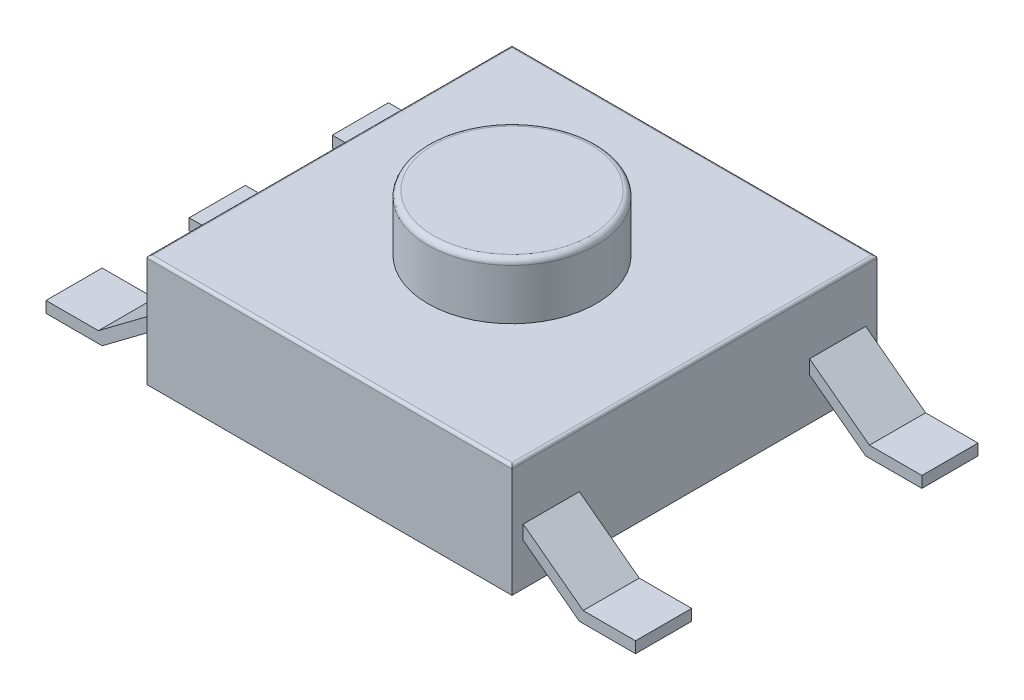
from build123d import *

# Parameters (mm, degrees)
SKETCH1_W           = 6.5
SKETCH1_H           = 6.5
BOSS_EXTRUDE1_DEPTH = 2
SKETCH2_R           = 1.5
BOSS_EXTRUDE2_DEPTH = 1
FILLET1_R           = 0.1
FILLET2_R           = 0.05
BOSS_EXTRUDE3_DEPTH = 6.5
SKETCH4_W           = 2
SKETCH4_H           = 1.55
SKETCH4_H_2         = 4.1
SKETCH4_H_3         = 0.2
CUT_EXTRUDE1_DEPTH  = 4


with BuildPart() as part:
    # Sketch1 → Boss-Extrude1 (new body)
    with BuildSketch(Plane(origin=(0, 0, 0), x_dir=(1, 0, 0), z_dir=(0, 1, 0))):
        with Locations((3.25, 3.25)):
            Rectangle(SKETCH1_W, SKETCH1_H)
    extrude(amount=BOSS_EXTRUDE1_DEPTH)

    # Sketch2 → Boss-Extrude2 (add)
    with BuildSketch(Plane(origin=(0, 2, 0), x_dir=(1, 0, 0), z_dir=(0, 1, 0))):
        with Locations((3.25, 3.25)):
            Circle(SKETCH2_R)
    extrude(amount=BOSS_EXTRUDE2_DEPTH)

    # Fillet1
    fillet1_edges = [part.edges().sort_by_distance(p)[0] for p in [
        (1.75, 3, -3.25),
    ]]
    fillet(fillet1_edges, radius=FILLET1_R)

    # Fillet2
    fillet2_edges = [part.edges().sort_by_distance(p)[0] for p in [
        (6.5, 2, -3.25),
        (3.25, 2, -6.5),
        (0, 2, -3.25),
        (3.25, 2, 0),
    ]]
    fillet(fillet2_edges, radius=FILLET2_R)

    # Sketch3 → Boss-Extrude3 (add, through all)
    with BuildSketch(Plane.XY):
        Polygon((6.5, 1), (7.566666667, 0.2), (8.5, 0.2), (8.5, 0), (7.5, 0), (6.5, 0.75), align=None)
        Polygon((-2, 0), (-1, 0), (0, 0.75), (0, 1), (-1.066666667, 0.2), (-2, 0.2), align=None)
    extrude(amount=-BOSS_EXTRUDE3_DEPTH)

    # Sketch4 → Cut-Extrude1 (cut, through all)
    with BuildSketch(Plane(origin=(0, 0, 0), x_dir=(-1, 0, 0), z_dir=(0, -1, 0))):
        with Locations((1, 1.975)):
            Rectangle(SKETCH4_W, SKETCH4_H)
        with Locations((1, 4.525)):
            Rectangle(SKETCH4_W, SKETCH4_H)
        with Locations((-7.5, 3.25)):
            Rectangle(SKETCH4_W, SKETCH4_H_2)
        with Locations((1, 0.1)):
            Rectangle(SKETCH4_W, SKETCH4_H_3)
        with Locations((1, 6.4)):
            Rectangle(SKETCH4_W, SKETCH4_H_3)
        with Locations((-7.5, 6.4)):
            Rectangle(SKETCH4_W, SKETCH4_H_3)
        with Locations((-7.5, 0.1)):
            Rectangle(SKETCH4_W, SKETCH4_H_3)
    extrude(amount=-CUT_EXTRUDE1_DEPTH, mode=Mode.SUBTRACT)


solid = part.part
